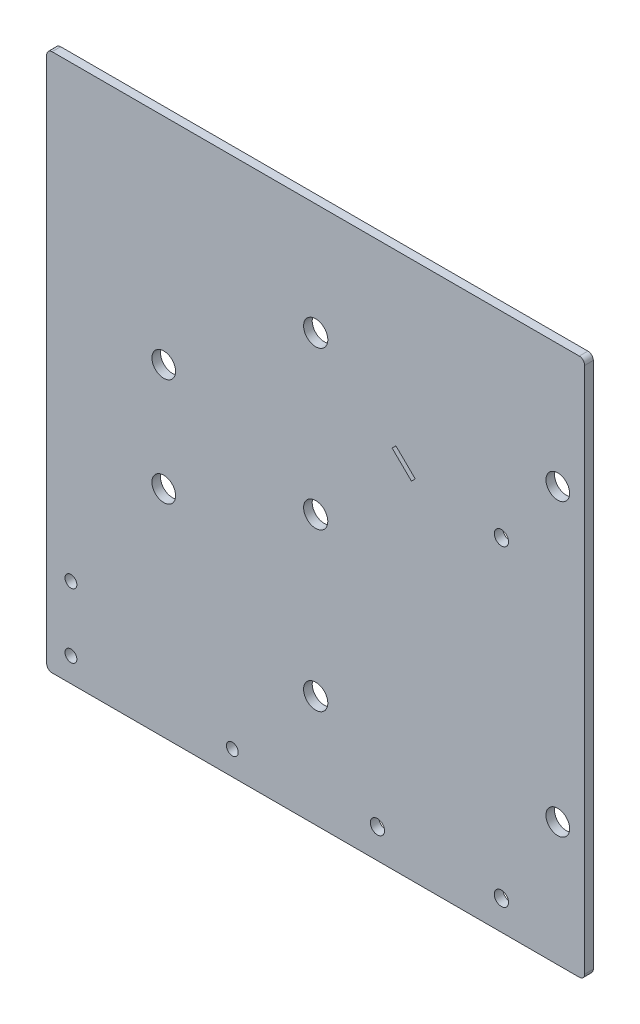
from build123d import *

# Parameters (mm, degrees)
SKETCH1_W           = 100
SKETCH1_H           = 100
BOSS_EXTRUDE1_DEPTH = 1.6
SKETCH3_R           = 2.2479
SKETCH3_R_2         = 1.325
SKETCH3_R_3         = 2.25
SKETCH3_R_4         = 2.2
SKETCH3_R_5         = 1.1
CUT_EXTRUDE2_DEPTH  = 71.728777736
FILLET1_R           = 1
CUT_EXTRUDE4_DEPTH  = 71.728777736


with BuildPart() as part:
    # Sketch1 → Boss-Extrude1 (new body)
    with BuildSketch(Plane.XY):
        Rectangle(SKETCH1_W, SKETCH1_H)
    extrude(amount=BOSS_EXTRUDE1_DEPTH)

    # Sketch3 → Cut-Extrude2 (cut, through all)
    with BuildSketch(Plane(origin=(0, 0, 1.6), x_dir=(-1, 0, 0), z_dir=(0, 0, -1))):
        Circle(SKETCH3_R)
        with Locations((-34.525, -44.525)):
            Circle(SKETCH3_R_2)
        with Locations((0, -29.25)):
            Circle(SKETCH3_R_3)
        with Locations((-45, -27)):
            Circle(SKETCH3_R_4)
        with Locations((0, 29.25)):
            Circle(SKETCH3_R_3)
        with Locations((-45, 27)):
            Circle(SKETCH3_R_4)
        with Locations((-34.525, 13.525)):
            Circle(SKETCH3_R_2)
        with Locations((15.5, -45.5)):
            Circle(SKETCH3_R_5)
        with Locations((45.5, -45.5)):
            Circle(SKETCH3_R_5)
        with Locations((45.5, -33.5)):
            Circle(SKETCH3_R_5)
        with Locations((-11.475, -44.525)):
            Circle(SKETCH3_R_2)
        with Locations((28.244666378, -9.999429886)):
            Circle(SKETCH3_R_4)
        with Locations((28.244666378, 10.000570114)):
            Circle(SKETCH3_R_4)
    extrude(amount=CUT_EXTRUDE2_DEPTH, mode=Mode.SUBTRACT)

    # Fillet1
    fillet1_edges = [part.edges().sort_by_distance(p)[0] for p in [
        (-50, -50, 0.8),
        (-50, 50, 0.8),
        (50, -50, 0.8),
        (50, 50, 0.8),
    ]]
    fillet(fillet1_edges, radius=FILLET1_R)

    # Sketch5 → Cut-Extrude4 (cut, through all)
    with BuildSketch(Plane(origin=(0, 0, 0), x_dir=(-1, 0, 0), z_dir=(0, 0, -1))):
        Polygon((-14.207463079, 17.79554595), (-17.804907195, 14.265775174), (-18.505268384, 14.979563801), (-14.907824268, 18.509334578), align=None)
    extrude(amount=-CUT_EXTRUDE4_DEPTH, mode=Mode.SUBTRACT)


solid = part.part
